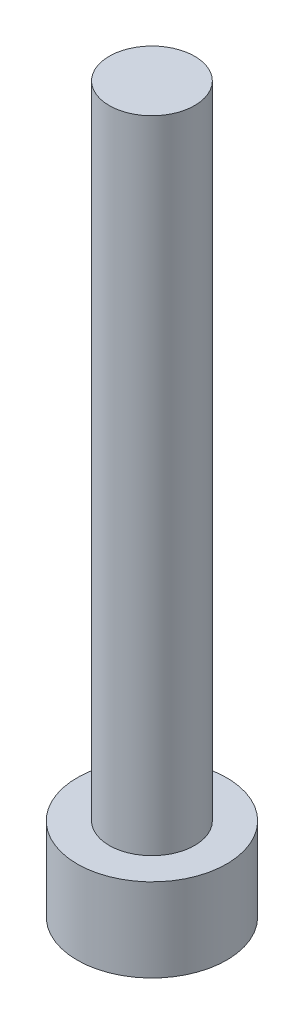
from build123d import *

# Parameters (mm, degrees)
SKETCH_1_R          = 3.5
EXTRUDE_1_DEPTH     = 3.9
SKETCH_2_R          = 2
EXTRUDE_2_DEPTH     = 30
CUT_EXTRUDE_1_DEPTH = 2.4


with BuildPart() as part:
    # 草图1 → 凸台-拉伸1 (new body)
    with BuildSketch(Plane(origin=(0, 0, 0), x_dir=(1, 0, 0), z_dir=(0, 1, 0))):
        Circle(SKETCH_1_R)
    extrude(amount=EXTRUDE_1_DEPTH)

    # 草图2 → 凸台-拉伸2 (add)
    with BuildSketch(Plane(origin=(0, 3.9, 0), x_dir=(1, 0, 0), z_dir=(0, 1, 0))):
        Circle(SKETCH_2_R)
    extrude(amount=EXTRUDE_2_DEPTH)

    # 草图3 → 切除-拉伸1 (cut)
    with BuildSketch(Plane.XZ):
        Polygon((1.725, 0), (0.8625, 1.493893822), (-0.8625, 1.493893822), (-1.725, 0), (-0.8625, -1.493893822), (0.8625, -1.493893822), align=None)
    extrude(amount=-CUT_EXTRUDE_1_DEPTH, mode=Mode.SUBTRACT)


solid = part.part
